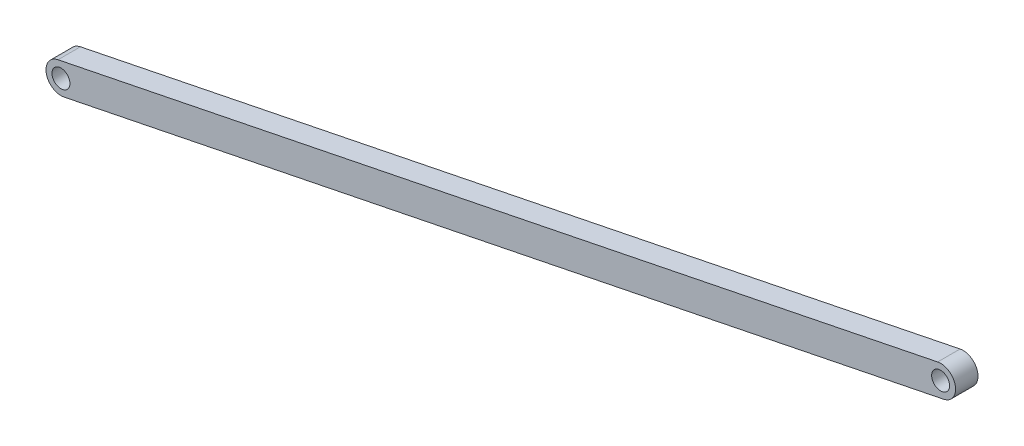
from build123d import *

# Parameters (mm, degrees)
SKETCH1_R           = 12
BOSS_EXTRUDE1_DEPTH = 30


with BuildPart() as part:
    # Sketch1 → Boss-Extrude1 (new body)
    with BuildSketch(Plane.XY):
        with BuildLine():
            Line((-3.969032643, 19.602213647), (1172.163786197, 257.744172248))
            ThreePointArc((1172.163786197, 257.744172248), (1195.735032488, 242.110991244), (1180.101851484, 218.539744953))
            Line((1180.101851484, 218.539744953), (3.969032643, -19.602213647))
            ThreePointArc((3.969032643, -19.602213647), (-19.602213647, -3.969032643), (-3.969032643, 19.602213647))
        make_face()
        Circle(SKETCH1_R, mode=Mode.SUBTRACT)
        with Locations((1176.132818841, 238.1419586)):
            Circle(SKETCH1_R, mode=Mode.SUBTRACT)
    extrude(amount=BOSS_EXTRUDE1_DEPTH)


solid = part.part
